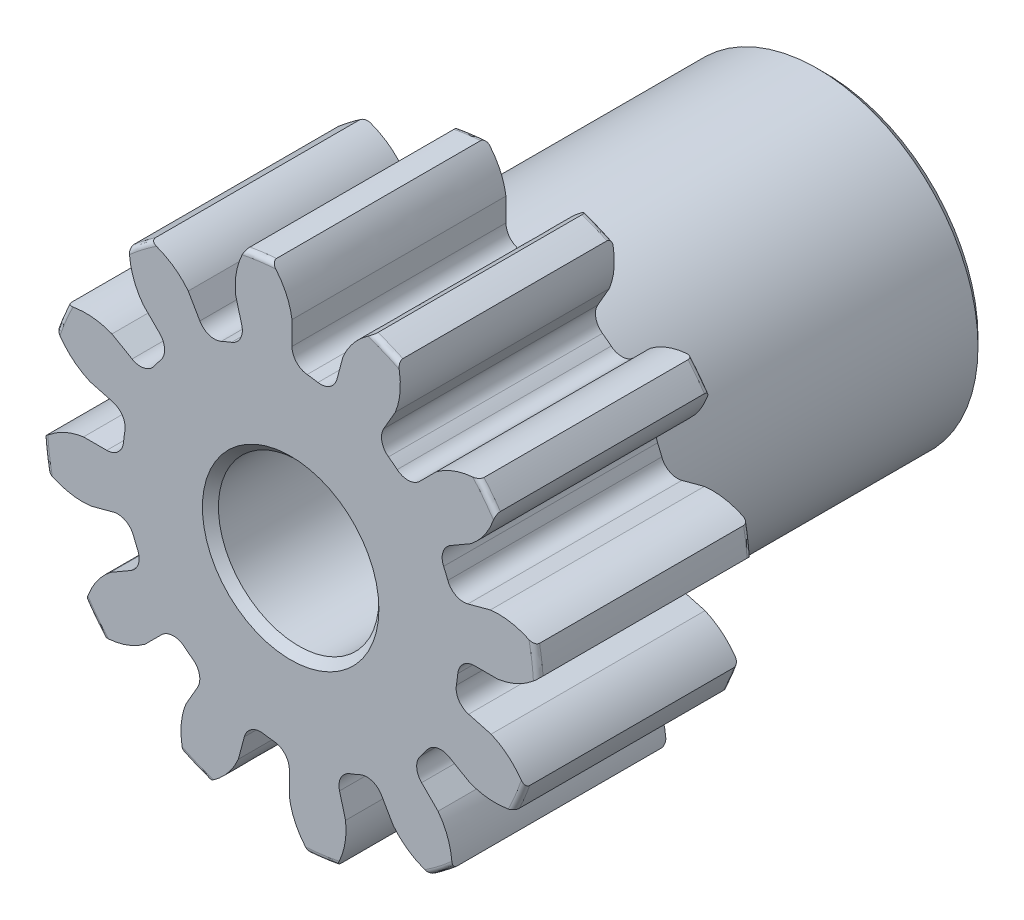
from build123d import *

# Parameters (mm, degrees)
SKETCH1_R                = 3.683
BOSS_EXTRUDE1_DEPTH      = 3.175
SKETCH2_W                = 4.7625
SKETCH2_H                = 2.38125
FILLET2_R                = 0.07366
CUT_EXTRUDE1_DEPTH       = 8.9375
FILLET1_R                = 0.2493645
CIRPATTERN1_COUNT        = 12
FILLET1_OF_CIRPATTERN1_R = 0.2493645
SKETCH5_R                = 1.190625
CUT_EXTRUDE2_DEPTH       = 8.9375
CHAMFER1_SIZE            = 0.1190625


with BuildPart() as part:
    # Sketch1 → Boss-Extrude1 (new body)
    with BuildSketch(Plane.XY):
        Circle(SKETCH1_R)
    extrude(amount=-BOSS_EXTRUDE1_DEPTH)

    # Sketch2 → Revolve1 (revolve)
    with BuildSketch(Plane(origin=(0, 0, 0), x_dir=(0, 0, -1), z_dir=(1, 0, 0))):
        with Locations((5.55625, 1.190625)):
            Rectangle(SKETCH2_W, SKETCH2_H)
    revolve(axis=Axis((0, 0, -3.175), (0, 0, -1)))

    # Fillet2
    fillet2_edges = [part.edges().sort_by_distance(p)[0] for p in [
        (-3.683, 0, 0),
        (-3.683, 0, -3.175),
        (0, -2.38125, -3.175),
    ]]
    fillet(fillet2_edges, radius=FILLET2_R)

    # Sketch4 → Cut-Extrude1 (cut, through all)
    with BuildSketch(Plane.XY):
        with BuildLine():
            Line((0.019723069, 3.073805482), (0.019723069, 2.492296961))
            ThreePointArc((0.019723069, 2.492296961), (0.325320975, 2.471052287), (0.626004375, 2.412478324))
            Line((0.626004375, 2.412478324), (0.776510199, 2.974172331))
            add(Edge.make_bspline(
                [(1.282468979, 3.507493348), (0.922821581, 3.314781549), (0.776510199, 2.974172331)],
                knots=[0, 0, 0, 1, 1, 1], degree=2))
            ThreePointArc((1.282468979, 3.507493348), (0.487464235, 3.702649712), (-0.330961552, 3.719906009))
            add(Edge.make_bspline(
                [(-0.330961552, 3.719906009), (-0.033446496, 3.440676928), (0.019723069, 3.073805482)],
                knots=[0, 0, 0, 1, 1, 1], degree=2))
        make_face()
    cut_extrude1 = extrude(amount=-CUT_EXTRUDE1_DEPTH, mode=Mode.SUBTRACT)

    # Fillet1
    fillet1_edges = [part.edges().sort_by_distance(p)[0] for p in [
        (0.626004375, 2.412478324, -1.5875),
        (0.019723069, 2.492296961, -1.5875),
    ]]
    fillet(fillet1_edges, radius=FILLET1_R)

    # CirPattern1: Cut-Extrude1 ×12 about axis
    cirpattern1_axis = Axis((0, 0, -3.175), (0, 0, 1))
    for i in range(1, CIRPATTERN1_COUNT):
        add(cut_extrude1.rotate(cirpattern1_axis, i * 360 / CIRPATTERN1_COUNT), mode=Mode.SUBTRACT)

    # Fillet1 of CirPattern1
    fillet1_of_cirpattern1_edges = [part.edges().sort_by_distance(p)[0] for p in [
        (-0.66410347, 2.402269702, -1.5875),
        (-1.229067802, 2.168254016, -1.5875),
        (-1.776265327, 1.748374854, -1.5875),
        (-2.148530948, 1.263229159, -1.5875),
        (-2.412478324, 0.626004375, -1.5875),
        (-2.492296961, 0.019723069, -1.5875),
        (-2.402269702, -0.66410347, -1.5875),
        (-2.168254016, -1.229067802, -1.5875),
        (-1.748374854, -1.776265327, -1.5875),
        (-1.263229159, -2.148530948, -1.5875),
        (-0.626004375, -2.412478324, -1.5875),
        (-0.019723069, -2.492296961, -1.5875),
        (0.66410347, -2.402269702, -1.5875),
        (1.229067802, -2.168254016, -1.5875),
        (1.776265327, -1.748374854, -1.5875),
        (2.148530948, -1.263229159, -1.5875),
        (2.412478324, -0.626004375, -1.5875),
        (2.492296961, -0.019723069, -1.5875),
        (2.402269702, 0.66410347, -1.5875),
        (2.168254016, 1.229067802, -1.5875),
        (1.748374854, 1.776265327, -1.5875),
        (1.263229159, 2.148530948, -1.5875),
    ]]
    fillet(fillet1_of_cirpattern1_edges, radius=FILLET1_OF_CIRPATTERN1_R)

    # Sketch5 → Cut-Extrude2 (cut, through all)
    with BuildSketch(Plane.XY):
        Circle(SKETCH5_R)
    extrude(amount=-CUT_EXTRUDE2_DEPTH, mode=Mode.SUBTRACT)

    # Chamfer1
    chamfer1_edges = [part.edges().sort_by_distance(p)[0] for p in [
        (0, -2.38125, -7.9375),
        (-1.190625, 0, -7.9375),
        (-1.190625, 0, 0),
    ]]
    chamfer(chamfer1_edges, length=CHAMFER1_SIZE)


solid = part.part
